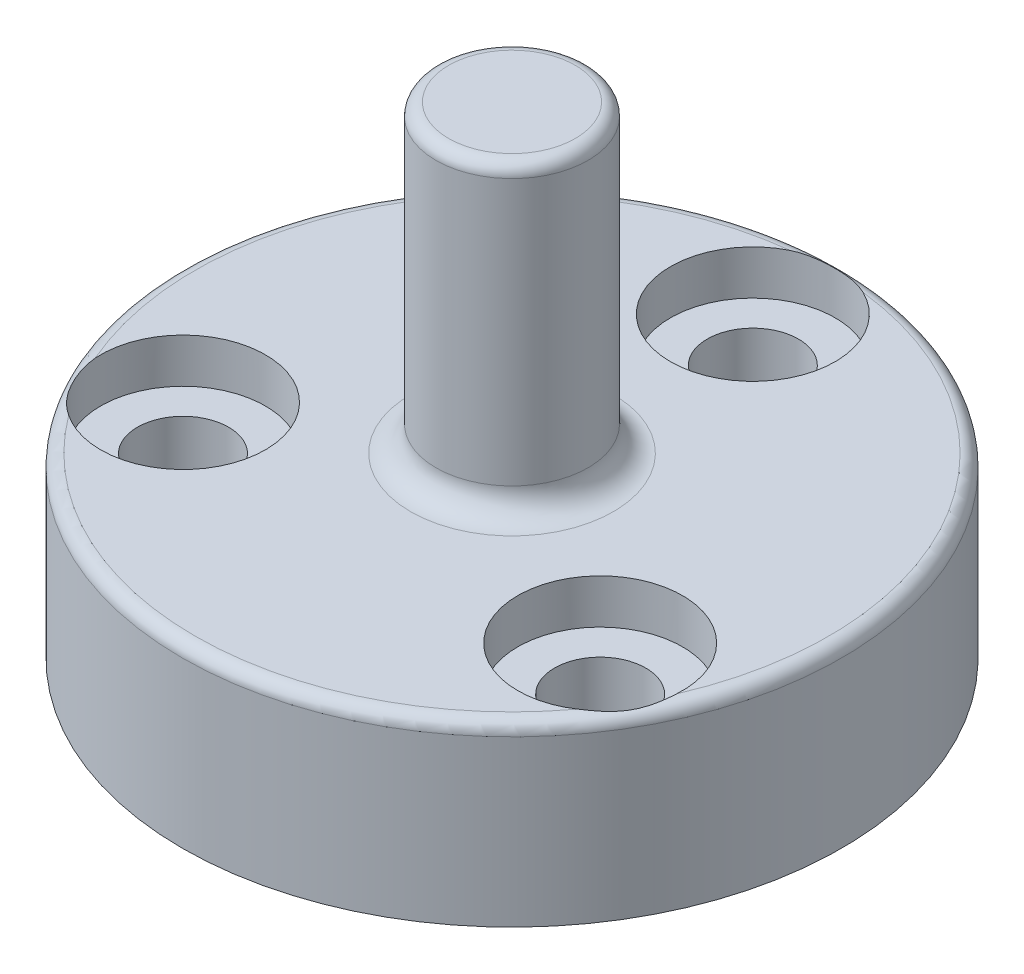
from build123d import *

# Parameters (mm, degrees)
SKETCH1_R                      = 13
BOSS_EXTRUDE1_DEPTH            = 7
SKETCH2_R                      = 7.165
CUT_EXTRUDE1_DEPTH             = 5.15
SKETCH3_R                      = 3
BOSS_EXTRUDE2_DEPTH            = 12
FILLET1_R                      = 1
FILLET1_2_R                    = 0.5
CBORE_FOR_M3_SHCS1_D           = 3.6
CBORE_FOR_M3_SHCS1_DEPTH       = 7
CBORE_FOR_M3_SHCS1_CBORE_D     = 6.5
CBORE_FOR_M3_SHCS1_CBORE_DEPTH = 1.75
FILLET2_R                      = 0.5


with BuildPart() as part:
    # Sketch1 → Boss-Extrude1 (new body)
    with BuildSketch(Plane(origin=(0, 0, 0), x_dir=(1, 0, 0), z_dir=(0, 1, 0))):
        Circle(SKETCH1_R)
    extrude(amount=BOSS_EXTRUDE1_DEPTH)

    # Sketch2 → Cut-Extrude1 (cut)
    with BuildSketch(Plane.XZ):
        Circle(SKETCH2_R)
    extrude(amount=-CUT_EXTRUDE1_DEPTH, mode=Mode.SUBTRACT)

    # Sketch3 → Boss-Extrude2 (add)
    with BuildSketch(Plane(origin=(0, 7, 0), x_dir=(1, 0, 0), z_dir=(0, 1, 0))):
        Circle(SKETCH3_R)
    extrude(amount=BOSS_EXTRUDE2_DEPTH)

    # Fillet1
    fillet1_edges = [part.edges().sort_by_distance(p)[0] for p in [
        (-3, 7, 0),
    ]]
    fillet(fillet1_edges, radius=FILLET1_R)

    # Fillet1 2
    fillet1_2_edges = [part.edges().sort_by_distance(p)[0] for p in [
        (-13, 7, 0),
    ]]
    fillet(fillet1_2_edges, radius=FILLET1_2_R)

    # CBORE for M3 SHCS1
    with Locations(Plane(origin=(0, 7, 0), x_dir=(1, 0, 0), z_dir=(0, 1, 0))):
        with Locations((0, 9.5), (8.227241336, -4.75), (-8.227241336, -4.75)):
            CounterBoreHole(CBORE_FOR_M3_SHCS1_D / 2, CBORE_FOR_M3_SHCS1_CBORE_D / 2, CBORE_FOR_M3_SHCS1_CBORE_DEPTH, depth=CBORE_FOR_M3_SHCS1_DEPTH)

    # Fillet2
    fillet2_edges = [part.edges().sort_by_distance(p)[0] for p in [
        (-3, 19, 0),
        (-7.165, 0, 0),
    ]]
    fillet(fillet2_edges, radius=FILLET2_R)


solid = part.part
